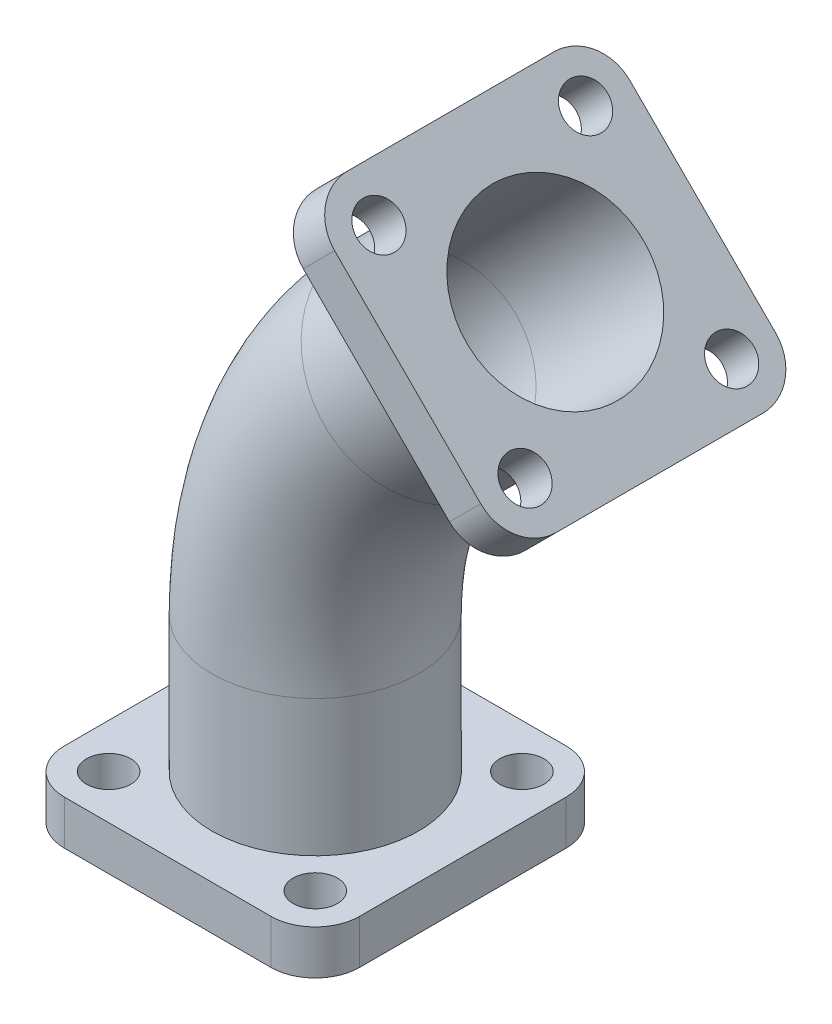
from build123d import *

# Parameters (mm, degrees)
SKETCH1_R           = 30
BOSS_EXTRUDE1_DEPTH = 15
SKETCH2_R           = 7.5
CUT_EXTRUDE1_DEPTH  = 15
SKETCH4_R           = 35
SKETCH4_R_2         = 30
BOSS_EXTRUDE2_DEPTH = 15
SKETCH7_R           = 7.5
SKETCH7_R_2         = 30
CUT_EXTRUDE2_DEPTH  = 15


with BuildPart() as part:
    # Sketch1 → Boss-Extrude1 (new body)
    with BuildSketch(Plane(origin=(0, 0, 0), x_dir=(1, 0, 0), z_dir=(0, 1, 0))):
        with BuildLine():
            Line((35, -50), (-35, -50))
            ThreePointArc((-35, -50), (-45.606601718, -45.606601718), (-50, -35))
            Line((-50, -35), (-50, 35))
            ThreePointArc((-50, 35), (-45.606601718, 45.606601718), (-35, 50))
            Line((-35, 50), (35, 50))
            ThreePointArc((35, 50), (45.606601718, 45.606601718), (50, 35))
            Line((50, 35), (50, -35))
            ThreePointArc((50, -35), (45.606601718, -45.606601718), (35, -50))
        make_face()
        with Locations(Location((0, 0, 0), (0, 0, 270))):
            Circle(SKETCH1_R, mode=Mode.SUBTRACT)
    extrude(amount=BOSS_EXTRUDE1_DEPTH)

    # Sketch2 → Cut-Extrude1 (cut)
    with BuildSketch(Plane(origin=(0, 15, 0), x_dir=(1, 0, 0), z_dir=(0, 1, 0))):
        with Locations(Location((-35, 35, 0), (0, 0, 270))):
            Circle(SKETCH2_R)
        with Locations(Location((35, 35, 0), (0, 0, 270))):
            Circle(SKETCH2_R)
        with Locations(Location((35, -35, 0), (0, 0, 270))):
            Circle(SKETCH2_R)
        with Locations(Location((-35, -35, 0), (0, 0, 270))):
            Circle(SKETCH2_R)
    extrude(amount=-CUT_EXTRUDE1_DEPTH, mode=Mode.SUBTRACT)

    # Sweep1: sweep along a path in Sketch5
    with BuildLine(Plane.XY) as sweep1_path:
        Line((0, 15), (0, 61.152236891))
        ThreePointArc((0, 61.152236891), (9.895660774, 110.901083099), (38.076118446, 153.076118446))
        Line((38.076118446, 153.076118446), (70.710678119, 185.710678119))
    # Sketch4 → Sweep1 (sweep)
    with BuildSketch(Plane(origin=(0, 15, 0), x_dir=(1, 0, 0), z_dir=(0, 1, 0))):
        Circle(SKETCH4_R)
        Circle(SKETCH4_R_2, mode=Mode.SUBTRACT)
    sweep(path=sweep1_path.line)

    # Sketch6 → Boss-Extrude2 (add)
    with BuildSketch(Plane(origin=(128.210678119, 128.210678119, 0), x_dir=(0, 0, -1), z_dir=(0.7071067811865477, 0.7071067811865474, 0))):
        with BuildLine():
            Line((35, 31.317279836), (-35, 31.317279836))
            ThreePointArc((-35, 31.317279836), (-45.606601718, 35.710678119), (-50, 46.317279836))
            Line((-50, 46.317279836), (-50, 116.317279836))
            ThreePointArc((-50, 116.317279836), (-45.606601718, 126.923881554), (-35, 131.317279836))
            Line((-35, 131.317279836), (35, 131.317279836))
            ThreePointArc((35, 131.317279836), (45.606601718, 126.923881554), (50, 116.317279836))
            Line((50, 116.317279836), (50, 46.317279836))
            ThreePointArc((50, 46.317279836), (45.606601718, 35.710678119), (35, 31.317279836))
        make_face()
    extrude(amount=BOSS_EXTRUDE2_DEPTH)

    # Sketch7 → Cut-Extrude2 (cut)
    with BuildSketch(Plane(origin=(138.817279836, 138.817279836, 0), x_dir=(0, 0, -1), z_dir=(0.7071067811865477, 0.7071067811865474, 0))):
        with Locations(Location((-35, 116.317279836, 0), (0, 0, 90))):
            Circle(SKETCH7_R)
        with Locations(Location((35, 116.317279836, 0), (0, 0, 90))):
            Circle(SKETCH7_R)
        with Locations(Location((35, 46.317279836, 0), (0, 0, 90))):
            Circle(SKETCH7_R)
        with Locations(Location((-35, 46.317279836, 0), (0, 0, 90))):
            Circle(SKETCH7_R)
        with Locations(Location((0, 81.317279836, 0), (0, 0, 90))):
            Circle(SKETCH7_R_2)
    extrude(amount=-CUT_EXTRUDE2_DEPTH, mode=Mode.SUBTRACT)


solid = part.part
